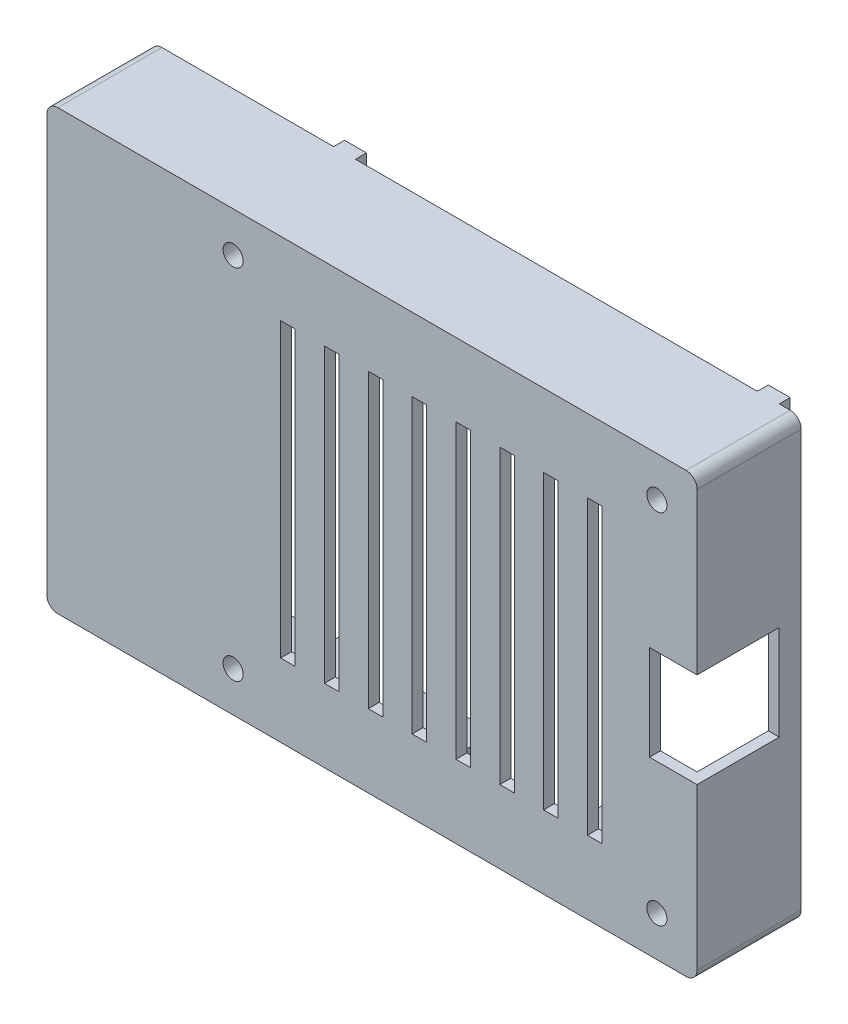
from build123d import *

# Parameters (mm, degrees)
SKETCH1_R             = 3
BOSS_EXTRUDE1_DEPTH   = 2.5
BOSS_EXTRUDE1_2_DEPTH = 2.5
BOSS_EXTRUDE1_3_DEPTH = 2.5
BOSS_EXTRUDE1_4_DEPTH = 2.5
SKETCH1_W             = 4
SKETCH1_H             = 4
BOSS_EXTRUDE1_5_DEPTH = 2.5
SKETCH2_W             = 89
SKETCH2_H             = 60
BOSS_EXTRUDE2_DEPTH   = 1.5
SKETCH3_W             = 89
SKETCH3_H             = 60
SKETCH3_W_2           = 86
SKETCH3_H_2           = 57
BOSS_EXTRUDE3_DEPTH   = 12.75
SKETCH4_W             = 10
SKETCH4_H             = 15.5
SKETCH4_W_2           = 9.5
SKETCH4_H_2           = 17
CUT_EXTRUDE1_DEPTH    = 1.5
SKETCH5_W             = 16
SKETCH5_H             = 8.5
SKETCH5_W_2           = 9
SKETCH5_H_2           = 9.5
CUT_EXTRUDE2_DEPTH    = 1.5
SKETCH6_W             = 11.25
SKETCH6_H             = 13
CUT_EXTRUDE3_DEPTH    = 6.5
SKETCH7_R             = 1.375
CUT_EXTRUDE4_DEPTH    = 5
SKETCH10_W            = 2
SKETCH10_H            = 40
CUT_EXTRUDE7_DEPTH    = 15.25
FILLET2_R             = 1.5
SKETCH12_W            = 3
SKETCH12_H            = 1.5
BOSS_EXTRUDE4_DEPTH   = 1.5


with BuildPart() as part:
    # Sketch1 → Boss-Extrude1 (new body)
    with BuildSketch(Plane.XY):
        Circle(SKETCH1_R)
    extrude(amount=BOSS_EXTRUDE1_DEPTH)



with BuildPart() as body_2:
    # Sketch1 → Boss-Extrude1 2 (new body)
    with BuildSketch(Plane.XY):
        with Locations((0, 49)):
            Circle(SKETCH1_R)
    extrude(amount=BOSS_EXTRUDE1_2_DEPTH)


with BuildPart() as body_3:
    # Sketch1 → Boss-Extrude1 3 (new body)
    with BuildSketch(Plane.XY):
        with Locations((-58, 0)):
            Circle(SKETCH1_R)
    extrude(amount=BOSS_EXTRUDE1_3_DEPTH)


with BuildPart() as body_4:
    # Sketch1 → Boss-Extrude1 4 (new body)
    with BuildSketch(Plane.XY):
        with Locations((-58, 49)):
            Circle(SKETCH1_R)
    extrude(amount=BOSS_EXTRUDE1_4_DEPTH)


with BuildPart() as body_5:
    # Sketch1 → Boss-Extrude1 5 (new body)
    with BuildSketch(Plane.XY):
        with Locations((-79.5, 24.5)):
            Rectangle(SKETCH1_W, SKETCH1_H)
    extrude(amount=BOSS_EXTRUDE1_5_DEPTH)


with BuildPart() as part_1:
    add(part.part)

    add(body_2.part)  # Boss-Extrude2 merges body 2

    add(body_3.part)  # Boss-Extrude2 merges body 3

    add(body_4.part)  # Boss-Extrude2 merges body 4
    # Sketch2 → Boss-Extrude2 (add)
    with BuildSketch(Plane.XY.offset(2.5)):
        with Locations((-39, 24.5)):
            Rectangle(SKETCH2_W, SKETCH2_H)
    extrude(amount=BOSS_EXTRUDE2_DEPTH)

    # Sketch3 → Boss-Extrude3 (add)
    with BuildSketch(Plane(origin=(0, 0, 2.5), x_dir=(-1, 0, 0), z_dir=(0, 0, -1))):
        with Locations((39, 24.5)):
            Rectangle(SKETCH3_W, SKETCH3_H)
        with Locations((39, 24.5)):
            Rectangle(SKETCH3_W_2, SKETCH3_H_2, mode=Mode.SUBTRACT)
    extrude(amount=BOSS_EXTRUDE3_DEPTH)

    # Sketch4 → Cut-Extrude1 (cut)
    with BuildSketch(Plane.ZY.offset(83.5)):
        with Locations((-5.25, 43.5)):
            Rectangle(SKETCH4_W, SKETCH4_H)
        with Locations((-5.25, 25.5)):
            Rectangle(SKETCH4_W, SKETCH4_H)
        with Locations((-5.5, 6.75)):
            Rectangle(SKETCH4_W_2, SKETCH4_H_2)
    extrude(amount=-CUT_EXTRUDE1_DEPTH, mode=Mode.SUBTRACT)

    # Sketch5 → Cut-Extrude2 (cut)
    with BuildSketch(Plane.XZ.offset(5.5)):
        with BuildLine():
            Line((-46.5, -10.25), (-53.5, -10.25))
            Line((-53.5, -10.25), (-53.5, -4.25))
            ThreePointArc((-53.5, -4.25), (-50, -0.75), (-46.5, -4.25))
            Line((-46.5, -4.25), (-46.5, -10.25))
        make_face()
        with Locations((-28.5, -6)):
            Rectangle(SKETCH5_W, SKETCH5_H)
        with Locations((-7.1, -5.5)):
            Rectangle(SKETCH5_W_2, SKETCH5_H_2)
    extrude(amount=-CUT_EXTRUDE2_DEPTH, mode=Mode.SUBTRACT)

    # Sketch6 → Cut-Extrude3 (cut)
    with BuildSketch(Plane(origin=(5.5, 0, 0), x_dir=(0, 0, -1), z_dir=(1, 0, 0))):
        with Locations((1.625, 24.5)):
            Rectangle(SKETCH6_W, SKETCH6_H)
    extrude(amount=-CUT_EXTRUDE3_DEPTH, mode=Mode.SUBTRACT)

    # Sketch7 → Cut-Extrude4 (cut, through all)
    with BuildSketch(Plane(origin=(0, 0, 0), x_dir=(-1, 0, 0), z_dir=(0, 0, -1))):
        Circle(SKETCH7_R)
        with Locations((0, 49)):
            Circle(SKETCH7_R)
        with Locations((58, 49)):
            Circle(SKETCH7_R)
        with Locations((58, 0)):
            Circle(SKETCH7_R)
    extrude(amount=-CUT_EXTRUDE4_DEPTH, mode=Mode.SUBTRACT)

    # Sketch10 → Cut-Extrude7 (cut, through all)
    with BuildSketch(Plane.XY.offset(4)):
        with Locations((-8.5, 24.5)):
            Rectangle(SKETCH10_W, SKETCH10_H)
        with Locations((-14.5, 24.5)):
            Rectangle(SKETCH10_W, SKETCH10_H)
        with Locations((-20.5, 24.5)):
            Rectangle(SKETCH10_W, SKETCH10_H)
        with Locations((-26.5, 24.5)):
            Rectangle(SKETCH10_W, SKETCH10_H)
        with Locations((-32.5, 24.5)):
            Rectangle(SKETCH10_W, SKETCH10_H)
        with Locations((-38.5, 24.5)):
            Rectangle(SKETCH10_W, SKETCH10_H)
        with Locations((-44.5, 24.5)):
            Rectangle(SKETCH10_W, SKETCH10_H)
        with Locations((-50.5, 24.5)):
            Rectangle(SKETCH10_W, SKETCH10_H)
    extrude(amount=-CUT_EXTRUDE7_DEPTH, mode=Mode.SUBTRACT)

    # Fillet2
    fillet2_edges = [part_1.edges().sort_by_distance(p)[0] for p in [
        (5.5, -5.5, -3.125),
        (5.5, 54.5, -3.125),
        (-83.5, 54.5, -3.125),
        (-83.5, -5.5, -3.125),
    ]]
    fillet(fillet2_edges, radius=FILLET2_R)

    # Sketch12 → Boss-Extrude4 (add)
    with BuildSketch(Plane(origin=(0, 0, -10.25), x_dir=(-1, 0, 0), z_dir=(0, 0, -1))):
        with Locations((-1, 53.75)):
            Rectangle(SKETCH12_W, SKETCH12_H)
        with Locations((57, 53.75)):
            Rectangle(SKETCH12_W, SKETCH12_H)
        with Locations((57, -4.75)):
            Rectangle(SKETCH12_W, SKETCH12_H)
        with Locations((-1, -4.75)):
            Rectangle(SKETCH12_W, SKETCH12_H)
    extrude(amount=BOSS_EXTRUDE4_DEPTH)


solid = Compound([body_5.part, part_1.part])
